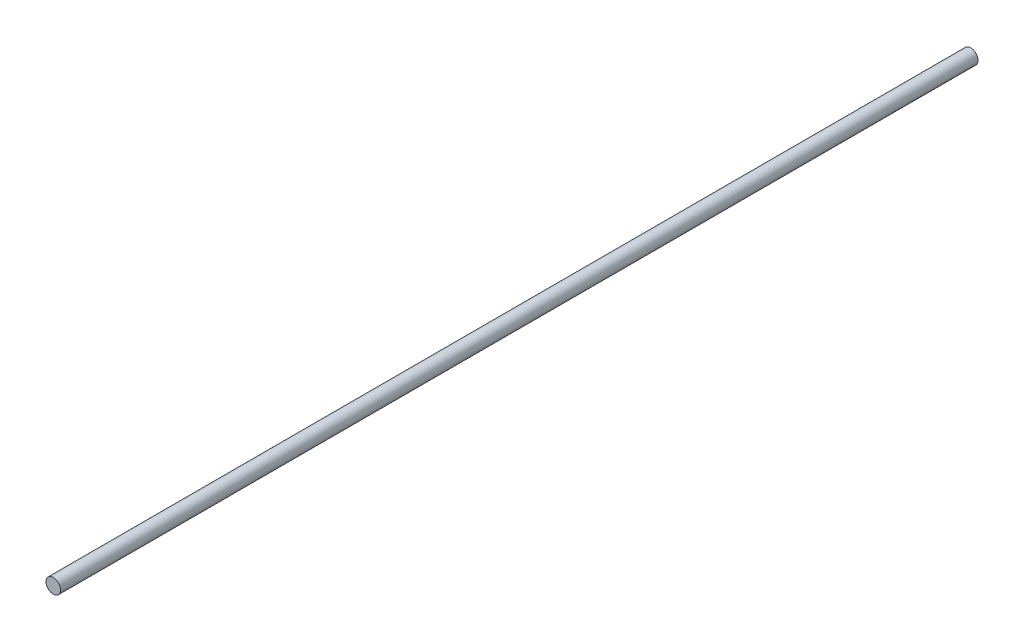
from build123d import *

# Parameters (mm, degrees)
CROQUIS1_R = 6.35


with BuildPart() as part:
    # Barrer1: sweep along a path in Croquis2
    with BuildLine(Plane(origin=(0, 0, 0), x_dir=(0, 0, -1), z_dir=(1, 0, 0))) as barrer1_path:
        Line((0, 0), (800, 0))
    # Croquis1 → Barrer1 (sweep)
    with BuildSketch(Plane.XY):
        Circle(CROQUIS1_R)
    sweep(path=barrer1_path.line)


solid = part.part
